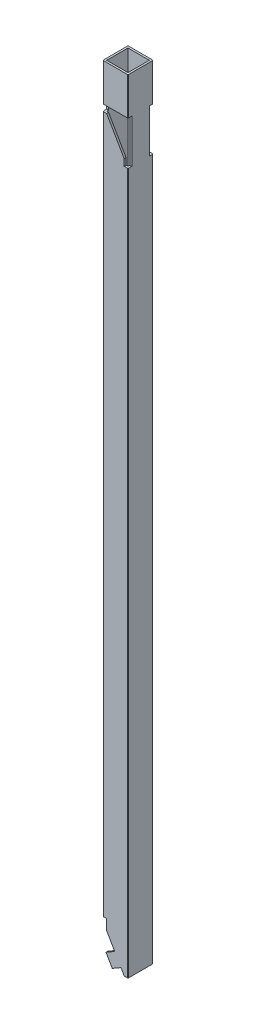
from build123d import *

# Parameters (mm, degrees)
SKETCH1_W           = 17
SKETCH1_H           = 17
BOSS_EXTRUDE1_DEPTH = 625
CUT_EXTRUDE1_DEPTH  = 626.639672655
CUT_EXTRUDE9_DEPTH  = 3


with BuildPart() as part:
    # Sketch1 → Boss-Extrude1 (new body)
    with BuildSketch(Plane(origin=(0, 0, 0), x_dir=(1, 0, 0), z_dir=(0, 1, 0))):
        with BuildLine():
            Line((0.5, 0), (19.5, 0))
            ThreePointArc((19.5, 0), (19.853553391, 0.146446609), (20, 0.5))
            Line((20, 0.5), (20, 19.5))
            ThreePointArc((20, 19.5), (19.853553391, 19.853553391), (19.5, 20))
            Line((19.5, 20), (0.5, 20))
            ThreePointArc((0.5, 20), (0.146446609, 19.853553391), (0, 19.5))
            Line((0, 19.5), (0, 0.5))
            ThreePointArc((0, 0.5), (0.146446609, 0.146446609), (0.5, 0))
        make_face()
        with Locations((10, 10)):
            Rectangle(SKETCH1_W, SKETCH1_H, mode=Mode.SUBTRACT)
    extrude(amount=BOSS_EXTRUDE1_DEPTH)

    # Sketch2 → Cut-Extrude1 (cut, through all)
    with BuildSketch(Plane.XY):
        Polygon((9.404700538, 15.155444566), (3, 26.248711306), (3, 34.641016151), (0, 34.641016151), (0, 0), (20, 0), (20, 2), (17, 2), (14.404700538, 6.495190528), (7.476497308, 2.495190528), (2.476497308, 11.155444566), align=None)
    extrude(amount=-CUT_EXTRUDE1_DEPTH, mode=Mode.SUBTRACT)

    # Sketch4 → Cut-Extrude9 (cut)
    with BuildSketch(Plane.XY):
        Polygon((20, 595), (20, 560.358983849), (17, 560.358983849), (17, 565.555136271), (3, 589.803847577), (0, 589.803847577), (0, 595), align=None)
    cut_extrude9 = extrude(amount=-CUT_EXTRUDE9_DEPTH, mode=Mode.SUBTRACT)

    # Mirror2: Cut-Extrude9 across plane
    add(cut_extrude9.mirror(Plane.XY.offset(-10)), mode=Mode.SUBTRACT)


solid = part.part
